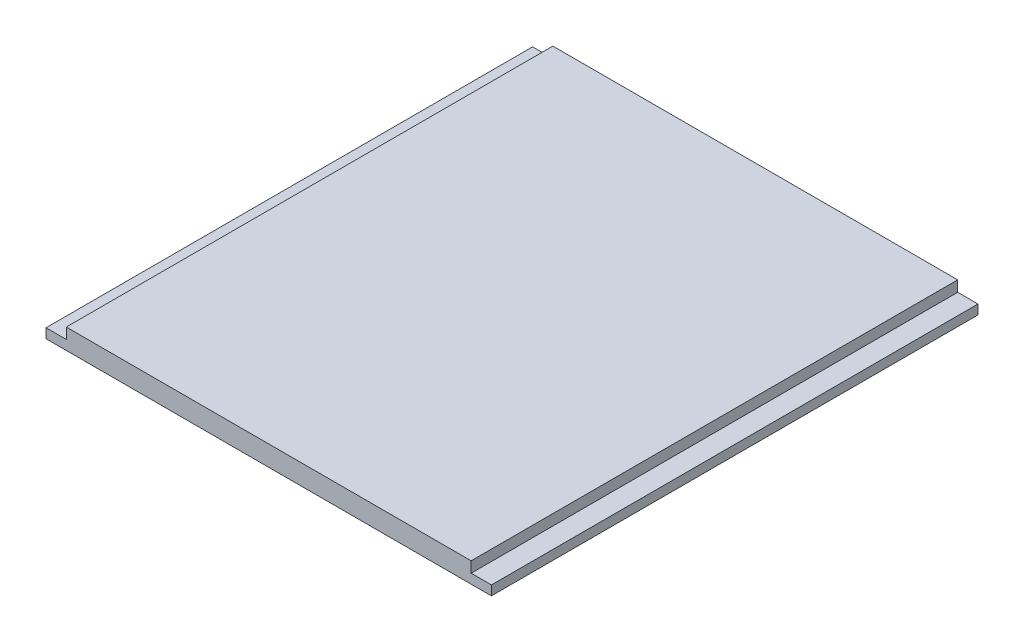
from build123d import *

# Parameters (mm, degrees)
SKETCH1_W           = 139.5
SKETCH1_H           = 152.4
BOSS_EXTRUDE1_DEPTH = 6.35
SKETCH2_W           = 6.35
SKETCH2_H           = 152.4
CUT_EXTRUDE1_DEPTH  = 3.375


with BuildPart() as part:
    # Sketch1 → Boss-Extrude1 (new body)
    with BuildSketch(Plane(origin=(0, 0, 0), x_dir=(1, 0, 0), z_dir=(0, 1, 0))):
        with Locations((69.75, 76.2)):
            Rectangle(SKETCH1_W, SKETCH1_H)
    extrude(amount=BOSS_EXTRUDE1_DEPTH)

    # Sketch2 → Cut-Extrude1 (cut)
    with BuildSketch(Plane(origin=(0, 6.35, 0), x_dir=(1, 0, 0), z_dir=(0, 1, 0))):
        with Locations((3.175, 76.2)):
            Rectangle(SKETCH2_W, SKETCH2_H)
        with Locations((136.325, 76.2)):
            Rectangle(SKETCH2_W, SKETCH2_H)
    extrude(amount=-CUT_EXTRUDE1_DEPTH, mode=Mode.SUBTRACT)


solid = part.part
